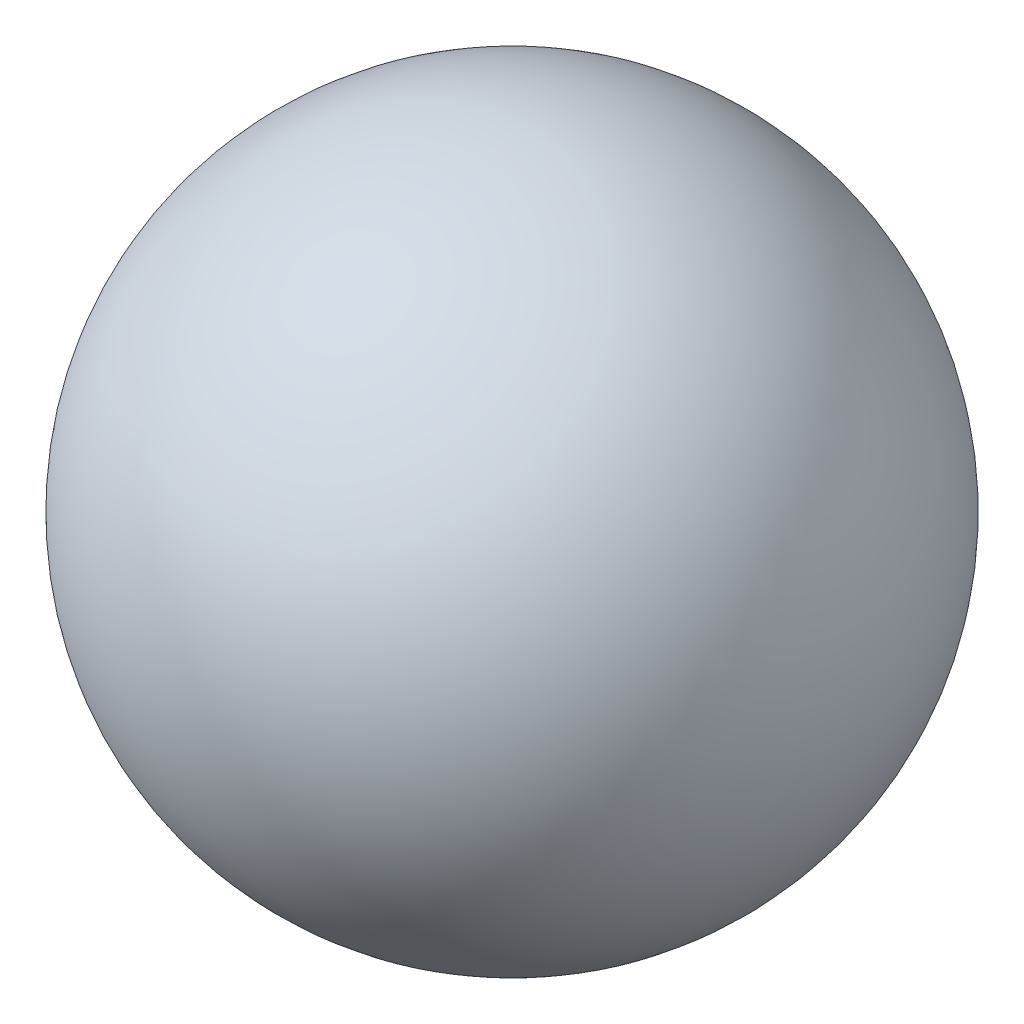
from build123d import *


with BuildPart() as part:
    # Sketch1 → Revolve2 (revolve)
    with BuildSketch(Plane.XY):
        with BuildLine():
            Line((0, -20), (0, 20))
            ThreePointArc((0, 20), (-20, 0), (0, -20))
        make_face()
    revolve(axis=Axis((0, 37.446568032, 0), (0, -1, 0)))


solid = part.part
